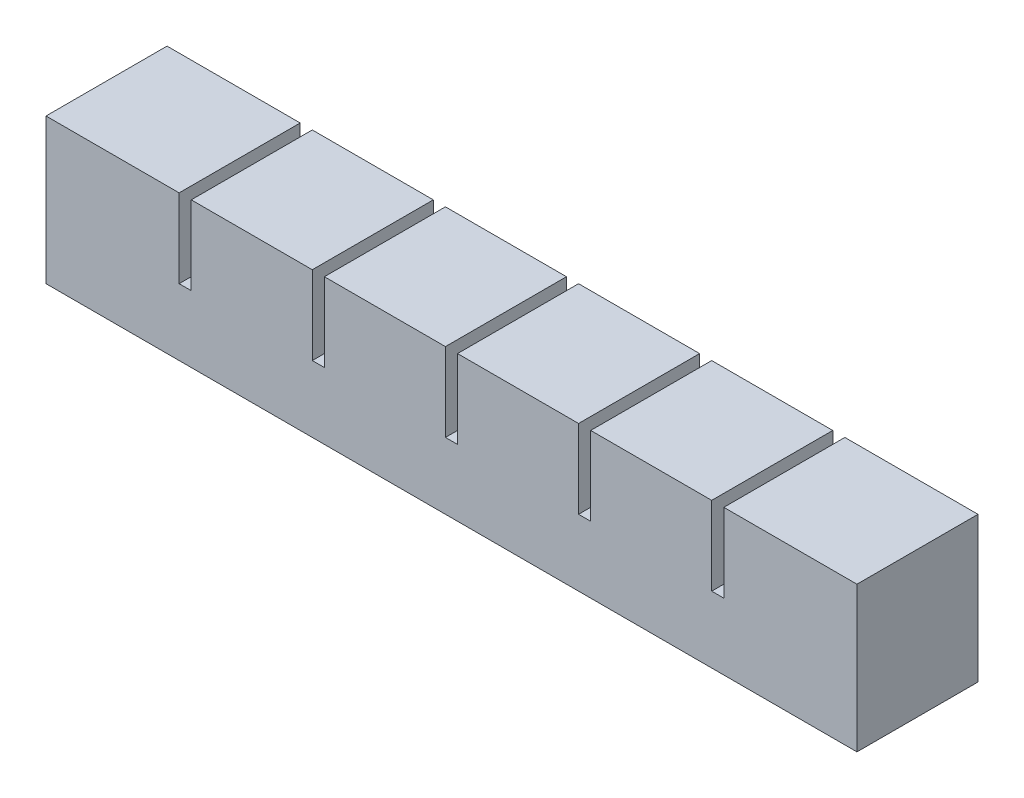
from build123d import *

# Parameters (mm, degrees)
SKETCH1_W           = 20
SKETCH1_H           = 18
BOSS_EXTRUDE1_DEPTH = 20
SKETCH2_W           = 12
SKETCH2_H           = 12
CUT_EXTRUDE1_DEPTH  = 14
SKETCH3_W           = 20
SKETCH3_H           = 5
BOSS_EXTRUDE2_DEPTH = 2
LPATTERN1_COUNT     = 6
LPATTERN1_PITCH     = 22
SKETCH4_W           = 20
SKETCH4_H           = 13
BOSS_EXTRUDE3_DEPTH = 2
SKETCH5_W           = 20
SKETCH5_H           = 18
BOSS_EXTRUDE4_DEPTH = 2
SKETCH6_W           = 122
SKETCH6_H           = 2
CUT_EXTRUDE2_DEPTH  = 2
SKETCH7_W           = 134
SKETCH7_H           = 20
BOSS_EXTRUDE5_DEPTH = 6


with BuildPart() as part:
    # Sketch1 → Boss-Extrude1 (new body)
    with BuildSketch(Plane.XY):
        with Locations((10, 9)):
            Rectangle(SKETCH1_W, SKETCH1_H)
    extrude(amount=BOSS_EXTRUDE1_DEPTH)

    # Sketch2 → Cut-Extrude1 (cut)
    with BuildSketch(Plane.XZ):
        with Locations((10, 10)):
            Rectangle(SKETCH2_W, SKETCH2_H)
    extrude(amount=-CUT_EXTRUDE1_DEPTH, mode=Mode.SUBTRACT)

    # Sketch3 → Boss-Extrude2 (add)
    with BuildSketch(Plane(origin=(20, 0, 0), x_dir=(0, 0, -1), z_dir=(1, 0, 0))):
        with Locations((-10, 2.5)):
            Rectangle(SKETCH3_W, SKETCH3_H)
    extrude(amount=BOSS_EXTRUDE2_DEPTH)


with BuildPart() as lpattern1_1:
    # LPattern1: pattern copy
    add(part.part.moved(Location(Vector(1, 0, 0) * (1 * LPATTERN1_PITCH))))


with BuildPart() as lpattern1_2:
    # LPattern1: pattern copy
    add(part.part.moved(Location(Vector(1, 0, 0) * (2 * LPATTERN1_PITCH))))


with BuildPart() as lpattern1_3:
    # LPattern1: pattern copy
    add(part.part.moved(Location(Vector(1, 0, 0) * (3 * LPATTERN1_PITCH))))


with BuildPart() as lpattern1_4:
    # LPattern1: pattern copy
    add(part.part.moved(Location(Vector(1, 0, 0) * (4 * LPATTERN1_PITCH))))


with BuildPart() as lpattern1_5:
    # LPattern1: pattern copy
    add(part.part.moved(Location(Vector(1, 0, 0) * (5 * LPATTERN1_PITCH))))


with BuildPart() as lpattern1_4_1:
    add(lpattern1_4.part)

    # Combine1: union LPattern1_5, part, LPattern1_1, LPattern1_2, LPattern1_3
    add(lpattern1_5.part)
    add(part.part)
    add(lpattern1_1.part)
    add(lpattern1_2.part)
    add(lpattern1_3.part)

    # Sketch4 → Boss-Extrude3 (add)
    with BuildSketch(Plane(origin=(130, 0, 0), x_dir=(0, 0, -1), z_dir=(1, 0, 0))):
        with Locations((-10, 11.5)):
            Rectangle(SKETCH4_W, SKETCH4_H)
    extrude(amount=BOSS_EXTRUDE3_DEPTH)

    # Sketch5 → Boss-Extrude4 (add)
    with BuildSketch(Plane.ZY):
        with Locations((10, 9)):
            Rectangle(SKETCH5_W, SKETCH5_H)
    extrude(amount=BOSS_EXTRUDE4_DEPTH)

    # Sketch6 → Cut-Extrude2 (cut)
    with BuildSketch(Plane(origin=(0, 0, 0), x_dir=(-1, 0, 0), z_dir=(0, -1, 0))):
        with Locations((-65, -10)):
            Rectangle(SKETCH6_W, SKETCH6_H)
    extrude(amount=-CUT_EXTRUDE2_DEPTH, mode=Mode.SUBTRACT)

    # Sketch7 → Boss-Extrude5 (add)
    with BuildSketch(Plane(origin=(0, 0, 0), x_dir=(-1, 0, 0), z_dir=(0, -1, 0))):
        with Locations((-65, -10)):
            Rectangle(SKETCH7_W, SKETCH7_H)
    extrude(amount=BOSS_EXTRUDE5_DEPTH)


solid = lpattern1_4_1.part
